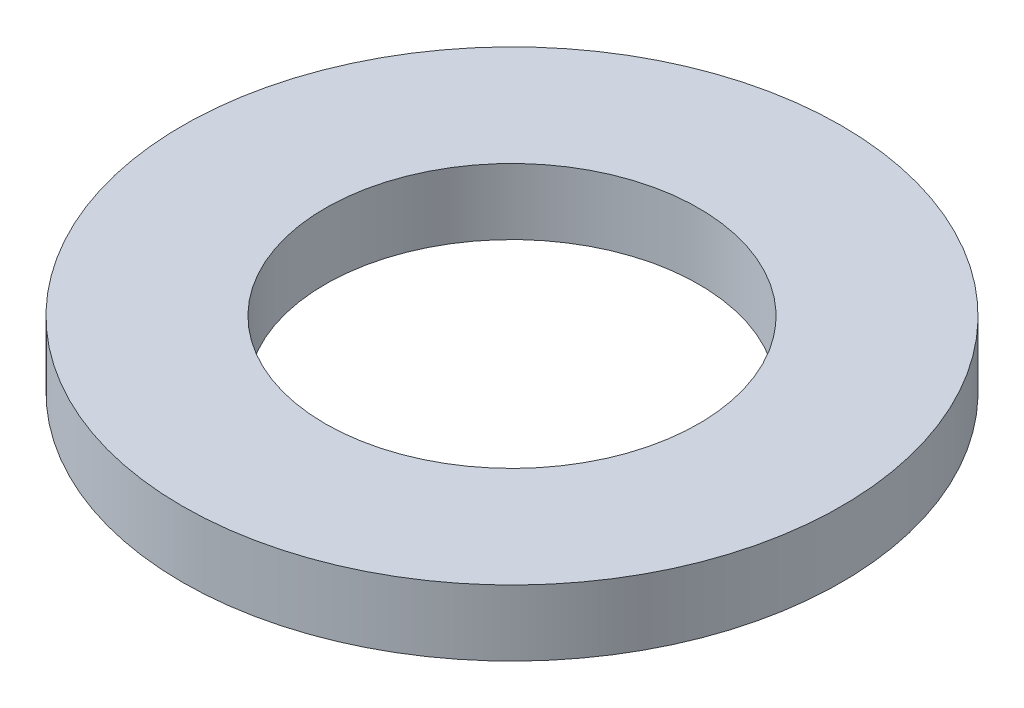
from build123d import *

# Parameters (mm, degrees)
SKETCH1_W = 6.5
SKETCH1_H = 3


with BuildPart() as part:
    # Sketch1 → Revolve1 (revolve)
    with BuildSketch(Plane.XY):
        with Locations((-11.75, -1.5)):
            Rectangle(SKETCH1_W, SKETCH1_H)
    revolve(axis=Axis((0, 2.968309859, 0), (0, -1, 0)))


solid = part.part
